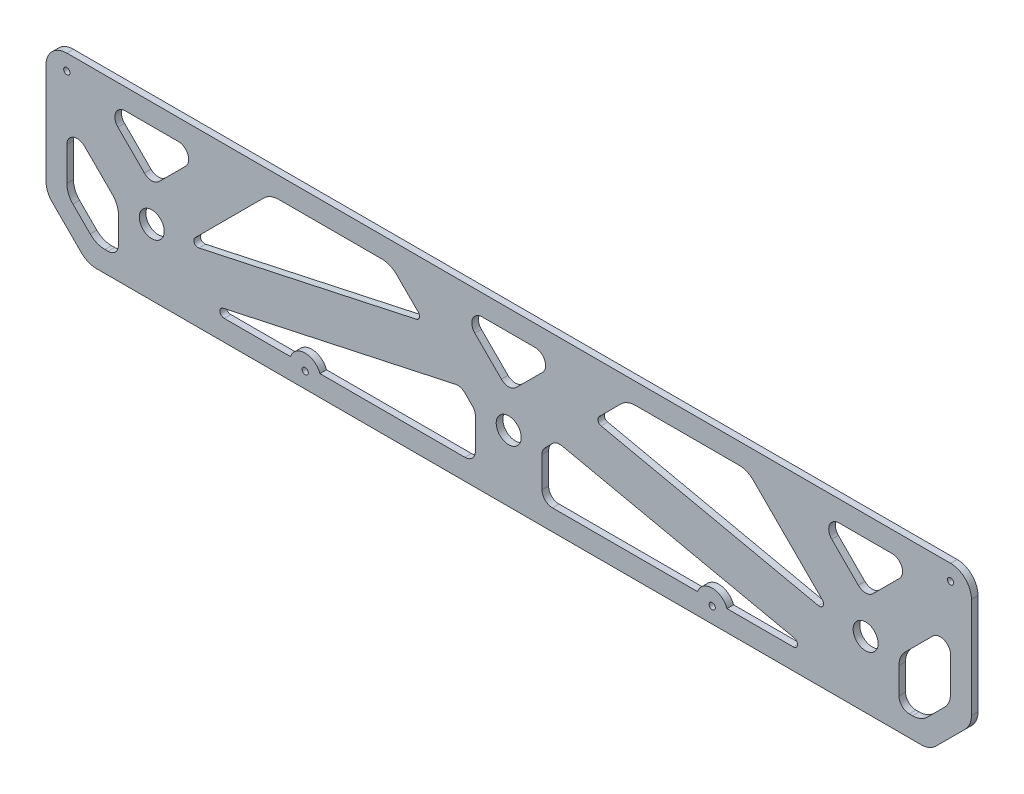
from build123d import *

# Parameters (mm, degrees)
SKETCH1_R           = 1.5
SKETCH1_R_2         = 5.999572562
SKETCH1_R_3         = 6
BOSS_EXTRUDE1_DEPTH = 3.175
FILLET1_R           = 10
FILLET2_R           = 5
FILLET3_R           = 5
FILLET4_R           = 5
FILLET5_R           = 2


with BuildPart() as part:
    # Sketch1 → Boss-Extrude1 (new body)
    with BuildSketch(Plane.XY):
        with BuildLine():
            ThreePointArc((0, 24.142135624), (0.761204675, 20.3153013), (2.928932188, 17.071067812))
            Line((2.928932188, 17.071067812), (17.071067812, 2.928932188))
            ThreePointArc((17.071067812, 2.928932188), (20.3153013, 0.761204675), (24.142135624, 0))
            Line((24.142135624, 0), (420.357864376, 0))
            ThreePointArc((420.357864376, 0), (424.1846987, 0.761204675), (427.428932188, 2.928932188))
            Line((427.428932188, 2.928932188), (441.571067812, 17.071067812))
            ThreePointArc((441.571067812, 17.071067812), (443.738795325, 20.3153013), (444.5, 24.142135624))
            Line((444.5, 24.142135624), (444.5, 72.55))
            ThreePointArc((444.5, 72.55), (441.571067812, 79.621067812), (434.5, 82.55))
            Line((434.5, 82.55), (10, 82.55))
            ThreePointArc((10, 82.55), (2.928932188, 79.621067812), (0, 72.55))
            Line((0, 72.55), (0, 24.142135624))
        make_face()
        with Locations((124.487832174, 7.5)):
            Circle(SKETCH1_R, mode=Mode.SUBTRACT)
        with BuildLine():
            ThreePointArc((12.928932188, 21.213203436), (10.761204675, 24.457436924), (10, 28.284271247))
            Line((10, 28.284271247), (10, 56.550427438))
            Line((10, 56.550427438), (34.800427438, 31.75))
            Line((34.800427438, 31.75), (34.800427438, 10))
            Line((34.800427438, 10), (28.284271247, 10))
            ThreePointArc((28.284271247, 10), (24.457436924, 10.761204675), (21.213203436, 12.928932188))
            Line((21.213203436, 12.928932188), (12.928932188, 21.213203436))
        make_face(mode=Mode.SUBTRACT)
        with Locations((50.8, 31.75)):
            Circle(SKETCH1_R_2, mode=Mode.SUBTRACT)
        with BuildLine():
            Line((199.331464685, 38.668535315), (206.25, 31.75))
            Line((206.25, 31.75), (206.25, 10))
            Line((206.25, 10), (131.558899986, 10))
            ThreePointArc((131.558899986, 10), (124.487832174, 15), (117.416764362, 10))
            Line((117.416764362, 10), (66.799572562, 10))
            Line((66.799572562, 10), (199.331464685, 38.668535315))
        make_face(mode=Mode.SUBTRACT)
        with Locations((320.012167826, 7.5)):
            Circle(SKETCH1_R, mode=Mode.SUBTRACT)
        with BuildLine():
            Line((238.25, 10), (238.25, 31.75))
            Line((238.25, 31.75), (245.168535315, 38.668535315))
            Line((245.168535315, 38.668535315), (377.700427438, 10))
            Line((377.700427438, 10), (327.083235638, 10))
            ThreePointArc((327.083235638, 10), (320.012167826, 15), (312.941100014, 10))
            Line((312.941100014, 10), (238.25, 10))
        make_face(mode=Mode.SUBTRACT)
        with Locations((222.25, 31.75)):
            Circle(SKETCH1_R_3, mode=Mode.SUBTRACT)
        with Locations((393.7, 31.75)):
            Circle(SKETCH1_R_2, mode=Mode.SUBTRACT)
        with BuildLine():
            Line((434.5, 56.550427438), (434.5, 28.284271247))
            ThreePointArc((434.5, 28.284271247), (433.738795325, 24.457436924), (431.571067812, 21.213203436))
            Line((431.571067812, 21.213203436), (423.286796564, 12.928932188))
            ThreePointArc((423.286796564, 12.928932188), (420.042563076, 10.761204675), (416.215728753, 10))
            Line((416.215728753, 10), (409.699572562, 10))
            Line((409.699572562, 10), (409.699572562, 31.75))
            Line((409.699572562, 31.75), (434.5, 56.550427438))
        make_face(mode=Mode.SUBTRACT)
        Polygon((50.8, 47.749572562), (25.999572562, 72.55), (75.600427438, 72.55), align=None, mode=Mode.SUBTRACT)
        Polygon((181.449572562, 56.550427438), (66.799572562, 31.75), (107.599572562, 72.55), (165.45, 72.55), align=None, mode=Mode.SUBTRACT)
        Polygon((247.05, 72.55), (222.25, 47.75), (197.45, 72.55), align=None, mode=Mode.SUBTRACT)
        with Locations((10, 75.05)):
            Circle(SKETCH1_R, mode=Mode.SUBTRACT)
        Polygon((263.050427438, 56.550427438), (279.05, 72.55), (336.900427438, 72.55), (377.700427438, 31.75), align=None, mode=Mode.SUBTRACT)
        Polygon((418.500427438, 72.55), (393.7, 47.749572562), (368.899572562, 72.55), align=None, mode=Mode.SUBTRACT)
        with Locations((434.5, 75.05)):
            Circle(SKETCH1_R, mode=Mode.SUBTRACT)
    extrude(amount=BOSS_EXTRUDE1_DEPTH)

    # Fillet1
    fillet1_edges = [part.edges().sort_by_distance(p)[0] for p in [
        (34.800427438, 31.75, 1.5875),
        (409.699572562, 31.75, 1.5875),
        (336.900427438, 72.55, 1.5875),
        (279.05, 72.55, 1.5875),
        (165.45, 72.55, 1.5875),
        (107.599572562, 72.55, 1.5875),
    ]]
    fillet(fillet1_edges, radius=FILLET1_R)

    # Fillet2
    fillet2_edges = [part.edges().sort_by_distance(p)[0] for p in [
        (245.168535315, 38.668535315, 1.5875),
        (238.25, 31.75, 1.5875),
        (238.25, 10, 1.5875),
        (34.800427438, 10, 1.5875),
        (409.699572562, 10, 1.5875),
        (206.25, 10, 1.5875),
        (206.25, 31.75, 1.5875),
        (199.331464685, 38.668535315, 1.5875),
    ]]
    fillet(fillet2_edges, radius=FILLET2_R)

    # Fillet3
    fillet3_edges = [part.edges().sort_by_distance(p)[0] for p in [
        (222.25, 47.75, 1.5875),
        (247.05, 72.55, 1.5875),
        (197.45, 72.55, 1.5875),
    ]]
    fillet(fillet3_edges, radius=FILLET3_R)

    # Fillet4
    fillet4_edges = [part.edges().sort_by_distance(p)[0] for p in [
        (10, 56.550427438, 1.5875),
        (434.5, 56.550427438, 1.5875),
        (75.600427438, 72.55, 1.5875),
        (25.999572562, 72.55, 1.5875),
        (50.8, 47.749572562, 1.5875),
        (393.7, 47.749572562, 1.5875),
        (418.500427438, 72.55, 1.5875),
        (368.899572562, 72.55, 1.5875),
    ]]
    fillet(fillet4_edges, radius=FILLET4_R)

    # Fillet5
    fillet5_edges = [part.edges().sort_by_distance(p)[0] for p in [
        (377.700427438, 10, 1.5875),
        (377.700427438, 31.75, 1.5875),
        (263.050427438, 56.550427438, 1.5875),
        (66.799572562, 31.75, 1.5875),
        (181.449572562, 56.550427438, 1.5875),
        (66.799572562, 10, 1.5875),
    ]]
    fillet(fillet5_edges, radius=FILLET5_R)


solid = part.part
